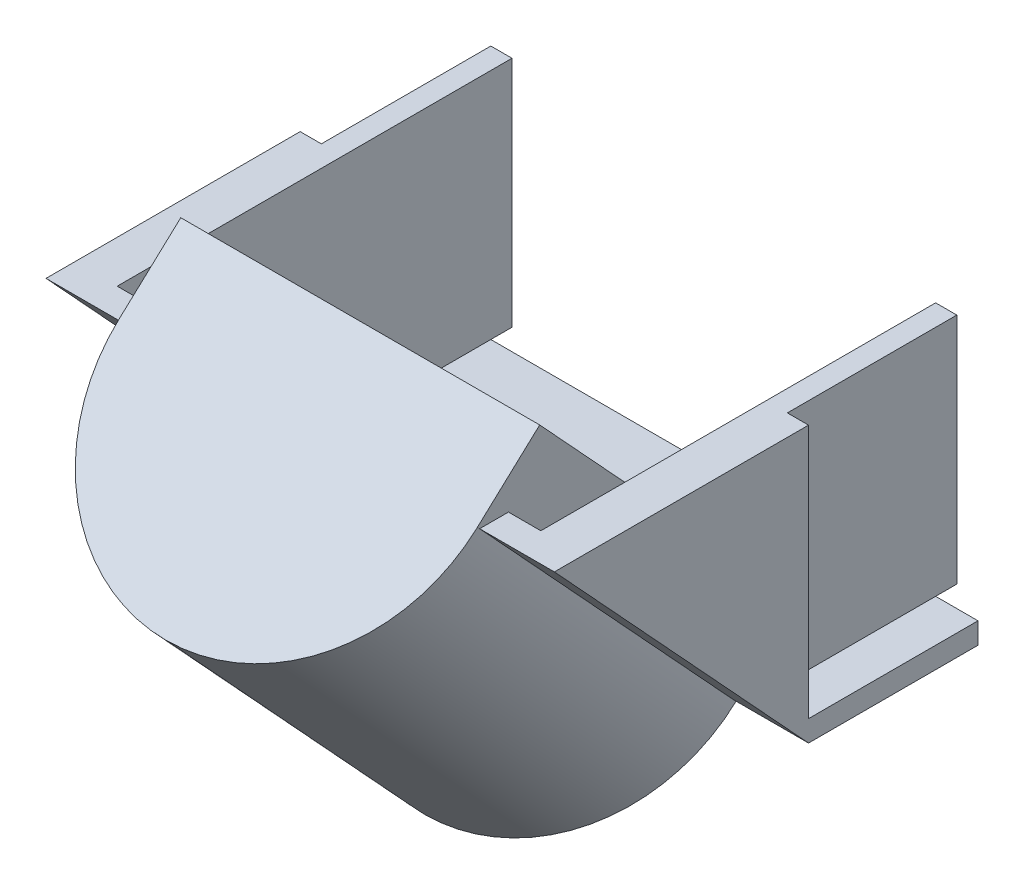
from build123d import *

# Parameters (mm, degrees)
BOSS_EXTRUDE2_DEPTH              = 76.2
BOSS_EXTRUDE2_DEPTH_BACK         = 76.2
SKETCH6_W                        = 152.4
SKETCH6_H                        = 6.35
SKETCH6_W_2                      = 6.35
SKETCH6_H_2                      = 69.85
BOSS_EXTRUDE3_DEPTH              = 50.8
CUT_EXTRUDE3_REACH               = 144.097
CUT_EXTRUDE3_OFFSET_FROM_SURFACE = 6.35
SKETCH7_W                        = 127
SKETCH7_H                        = 69.85
BOSS_EXTRUDE5_DEPTH              = 57.15


with BuildPart() as part:
    # Sketch4 → Boss-Extrude2 (new, two sides: drawn at the far end of the back side and taken through both)
    with BuildSketch(Plane(origin=(0, 0, 0), x_dir=(0, 0, -1), z_dir=(1, 0, 0)).offset(-BOSS_EXTRUDE2_DEPTH_BACK)):
        Polygon((0, 0), (0, 82.55), (-76.2, 82.55), align=None)
    extrude(amount=BOSS_EXTRUDE2_DEPTH + BOSS_EXTRUDE2_DEPTH_BACK)

    # Sketch6 → Boss-Extrude3 (add)
    with BuildSketch(Plane(origin=(0, 0, 0), x_dir=(-1, 0, 0), z_dir=(0, 0, -1))):
        with Locations((0, 3.175)):
            Rectangle(SKETCH6_W, SKETCH6_H)
        with Locations((-66.675, 47.625)):
            Rectangle(SKETCH6_W_2, SKETCH6_H_2)
        with Locations((66.675, 47.625)):
            Rectangle(SKETCH6_W_2, SKETCH6_H_2)
    extrude(amount=BOSS_EXTRUDE3_DEPTH)

    # Cut-Extrude3: up to this face of the body (flat: up to its plane, moved by the offset)
    cut_extrude3_end = Plane(part.part.faces().sort_by_distance((0, 41.275, 38.1))[0]).offset(-CUT_EXTRUDE3_OFFSET_FROM_SURFACE)
    # Sketch7 → Cut-Extrude3 (cut, up to the picked face)
    with BuildSketch(Plane(origin=(0, 0, 0), x_dir=(-1, 0, 0), z_dir=(0, 0, -1)), mode=Mode.PRIVATE) as cut_extrude3_sk1:
        with Locations((0, 47.625)):
            Rectangle(SKETCH7_W, SKETCH7_H)
    cut_extrude3_tool1 = split(extrude(cut_extrude3_sk1.sketch, amount=-CUT_EXTRUDE3_REACH, mode=Mode.PRIVATE), bisect_by=cut_extrude3_end, keep=Keep.BOTH, mode=Mode.PRIVATE)
    add(cut_extrude3_tool1.solids().sort_by(Axis((0, 47.625, 0), (0, 0, 1)))[0], mode=Mode.SUBTRACT)

    # Sketch8 → Boss-Extrude5 (add, symmetric)
    with BuildSketch(Plane(origin=(0, 41.275, 38.1), x_dir=(-1, 0, 0), z_dir=(0, -0.7348034446274878, -0.6782801027330659))):
        with BuildLine():
            Line((-53.798871559, 0), (-53.798871559, 25.4))
            Line((-53.798871559, 25.4), (53.798871559, 25.4))
            Line((53.798871559, 25.4), (53.798871559, 0))
            ThreePointArc((53.798871559, 0), (0, -53.798871559), (-53.798871559, 0))
        make_face()
    extrude(amount=BOSS_EXTRUDE5_DEPTH, both=True)


solid = part.part
